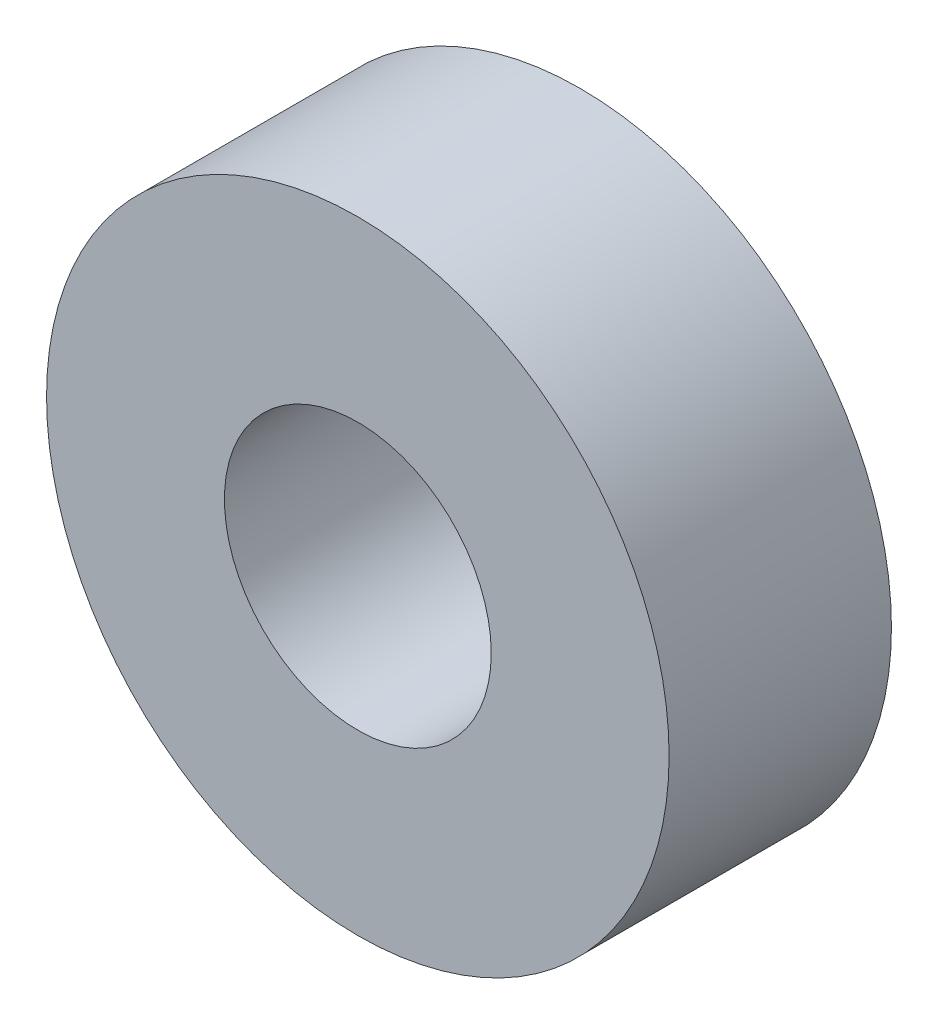
from build123d import *

# Parameters (mm, degrees)
SKETCH_1_R      = 7
SKETCH_1_R_2    = 3
EXTRUDE_1_DEPTH = 2.5


with BuildPart() as part:
    # 草图1 → 凸台-拉伸1 (new body, symmetric)
    with BuildSketch(Plane.XY):
        Circle(SKETCH_1_R)
        Circle(SKETCH_1_R_2, mode=Mode.SUBTRACT)
    extrude(amount=EXTRUDE_1_DEPTH, both=True)


solid = part.part
